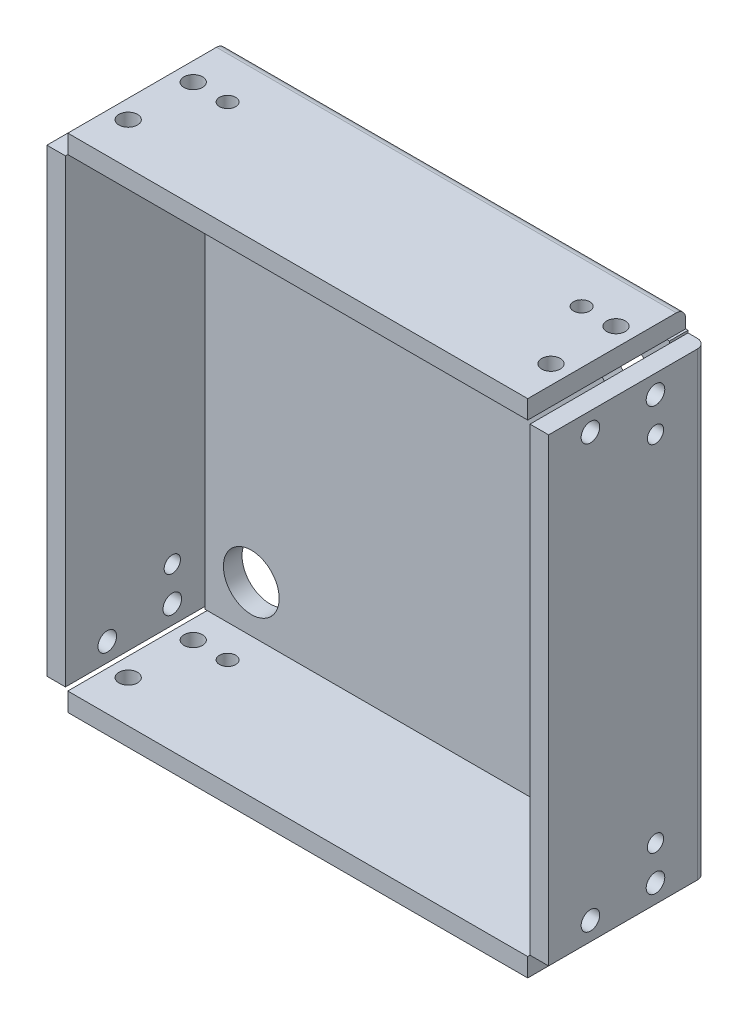
from build123d import *

# Parameters (mm, degrees)
SKETCH1_W           = 100
SKETCH1_H           = 100
SKETCH1_R           = 6
BOSS_EXTRUDE1_DEPTH = 4
SKETCH1_3_W         = 4
SKETCH1_3_H         = 99
SKETCH1_3_W_2       = 99
SKETCH1_3_H_2       = 4
BOSS_EXTRUDE3_DEPTH = 34
FILLET3_R           = 2
SKETCH2_R           = 2
SKETCH2_R_2         = 1.75
CUT_EXTRUDE1_DEPTH  = 4
SKETCH3_R           = 2
SKETCH3_R_2         = 1.75
CUT_EXTRUDE2_DEPTH  = 4
SKETCH4_R           = 2
SKETCH4_R_2         = 1.75
CUT_EXTRUDE3_DEPTH  = 4
SKETCH5_R           = 2
SKETCH5_R_2         = 1.75
CUT_EXTRUDE4_DEPTH  = 4


with BuildPart() as part:
    # Sketch1 → Boss-Extrude1 (new body)
    with BuildSketch(Plane.XY):
        with Locations((-48.16802168, -14.386178862)):
            Rectangle(SKETCH1_W, SKETCH1_H)
        with Locations((-88.16802168, -54.386178862)):
            Circle(SKETCH1_R, mode=Mode.SUBTRACT)
        with Locations((-8.16802168, -54.386178862)):
            Circle(SKETCH1_R, mode=Mode.SUBTRACT)
        with Locations((-8.16802168, 25.613821138)):
            Circle(SKETCH1_R, mode=Mode.SUBTRACT)
        with Locations((-88.16802168, 25.613821138)):
            Circle(SKETCH1_R, mode=Mode.SUBTRACT)
    extrude(amount=BOSS_EXTRUDE1_DEPTH)

    # Sketch1_3 → Boss-Extrude3 (add)
    with BuildSketch(Plane.XY):
        with Locations((-100.16802168, -14.386178862)):
            Rectangle(SKETCH1_3_W, SKETCH1_3_H)
        with Locations((-48.16802168, 37.613821138)):
            Rectangle(SKETCH1_3_W_2, SKETCH1_3_H_2)
        with Locations((3.83197832, -14.386178862)):
            Rectangle(SKETCH1_3_W, SKETCH1_3_H)
        with Locations((-48.16802168, -66.386178862)):
            Rectangle(SKETCH1_3_W_2, SKETCH1_3_H_2)
    extrude(amount=BOSS_EXTRUDE3_DEPTH)

    # Fillet3
    fillet3_edges = [part.edges().sort_by_distance(p)[0] for p in [
        (-102.16802168, -14.386178862, 0),
        (-48.16802168, 39.613821138, 0),
        (5.83197832, -14.386178862, 0),
        (-48.16802168, -68.386178862, 0),
    ]]
    fillet(fillet3_edges, radius=FILLET3_R)

    # Sketch2 → Cut-Extrude1 (cut)
    with BuildSketch(Plane.ZY.offset(102.16802168)):
        with Locations((25, 31.113821138)):
            Circle(SKETCH2_R)
        with Locations((25, -59.886178862)):
            Circle(SKETCH2_R)
        with Locations((11, 31.113821138)):
            Circle(SKETCH2_R)
        with Locations((11, -59.886178862)):
            Circle(SKETCH2_R)
        with Locations((11, 23.713821138)):
            Circle(SKETCH2_R_2)
        with Locations((11, -52.486178862)):
            Circle(SKETCH2_R_2)
    extrude(amount=-CUT_EXTRUDE1_DEPTH, mode=Mode.SUBTRACT)

    # Sketch3 → Cut-Extrude2 (cut)
    with BuildSketch(Plane.XZ.offset(68.386178862)):
        with Locations((-93.66802168, 25)):
            Circle(SKETCH3_R)
        with Locations((-2.66802168, 25)):
            Circle(SKETCH3_R)
        with Locations((-93.66802168, 11)):
            Circle(SKETCH3_R)
        with Locations((-2.66802168, 11)):
            Circle(SKETCH3_R)
        with Locations((-86.26802168, 11)):
            Circle(SKETCH3_R_2)
        with Locations((-9.56802168, 11)):
            Circle(SKETCH3_R_2)
    extrude(amount=-CUT_EXTRUDE2_DEPTH, mode=Mode.SUBTRACT)

    # Sketch4 → Cut-Extrude3 (cut)
    with BuildSketch(Plane(origin=(5.83197832, 0, 0), x_dir=(0, 0, -1), z_dir=(1, 0, 0))):
        with Locations((-25, -59.886178862)):
            Circle(SKETCH4_R)
        with Locations((-25, 31.113821138)):
            Circle(SKETCH4_R)
        with Locations((-11, -59.886178862)):
            Circle(SKETCH4_R)
        with Locations((-11, 31.113821138)):
            Circle(SKETCH4_R)
        with Locations((-11, -52.486178862)):
            Circle(SKETCH4_R_2)
        with Locations((-11, 23.713821138)):
            Circle(SKETCH4_R_2)
    extrude(amount=-CUT_EXTRUDE3_DEPTH, mode=Mode.SUBTRACT)

    # Sketch5 → Cut-Extrude4 (cut)
    with BuildSketch(Plane(origin=(0, 39.613821138, 0), x_dir=(1, 0, 0), z_dir=(0, 1, 0))):
        with Locations((-93.66802168, -25)):
            Circle(SKETCH5_R)
        with Locations((-2.66802168, -25)):
            Circle(SKETCH5_R)
        with Locations((-93.66802168, -11)):
            Circle(SKETCH5_R)
        with Locations((-2.66802168, -11)):
            Circle(SKETCH5_R)
        with Locations((-86.26802168, -11)):
            Circle(SKETCH5_R_2)
        with Locations((-10.06802168, -11)):
            Circle(SKETCH5_R_2)
    extrude(amount=-CUT_EXTRUDE4_DEPTH, mode=Mode.SUBTRACT)


solid = part.part
